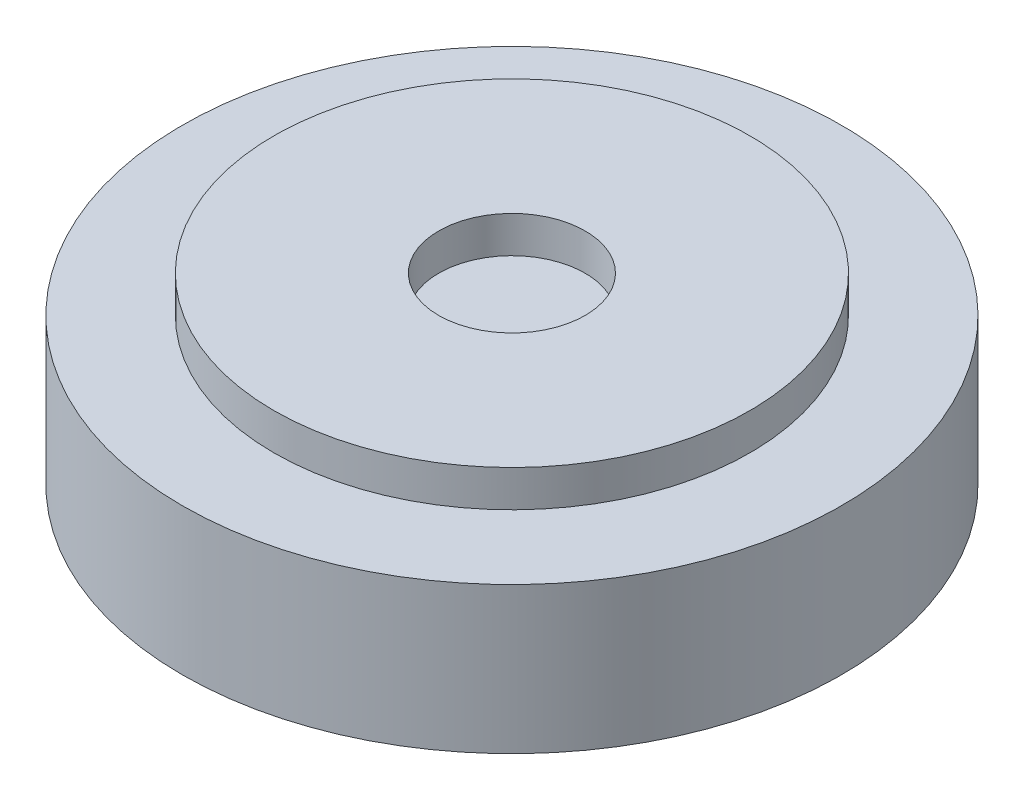
from build123d import *

# Parameters (mm, degrees)
SKETCH_1_R          = 9
EXTRUDE_1_DEPTH     = 5
SKETCH_2_OUTSIDE_W  = 25.188
SKETCH_2_OUTSIDE_H  = 25.188
SKETCH_2_OUTSIDE_R  = 6.5
CUT_EXTRUDE_1_DEPTH = 1
SKETCH_3_R          = 2
CUT_EXTRUDE_2_DEPTH = 1


with BuildPart() as part:
    # 草图1 → 凸台-拉伸1 (new body)
    with BuildSketch(Plane(origin=(0, 0, 0), x_dir=(1, 0, 0), z_dir=(0, 1, 0))):
        Circle(SKETCH_1_R)
    extrude(amount=EXTRUDE_1_DEPTH)

    # 草图2 outside → 切除-拉伸1 (cut)
    with BuildSketch(Plane(origin=(0, 5, 0), x_dir=(1, 0, 0), z_dir=(0, 1, 0))):
        Rectangle(SKETCH_2_OUTSIDE_W, SKETCH_2_OUTSIDE_H)
        Circle(SKETCH_2_OUTSIDE_R, mode=Mode.SUBTRACT)
    extrude(amount=-CUT_EXTRUDE_1_DEPTH, mode=Mode.SUBTRACT)

    # 草图3 → 切除-拉伸2 (cut)
    with BuildSketch(Plane(origin=(0, 5, 0), x_dir=(1, 0, 0), z_dir=(0, 1, 0))):
        Circle(SKETCH_3_R)
    extrude(amount=-CUT_EXTRUDE_2_DEPTH, mode=Mode.SUBTRACT)


solid = part.part
